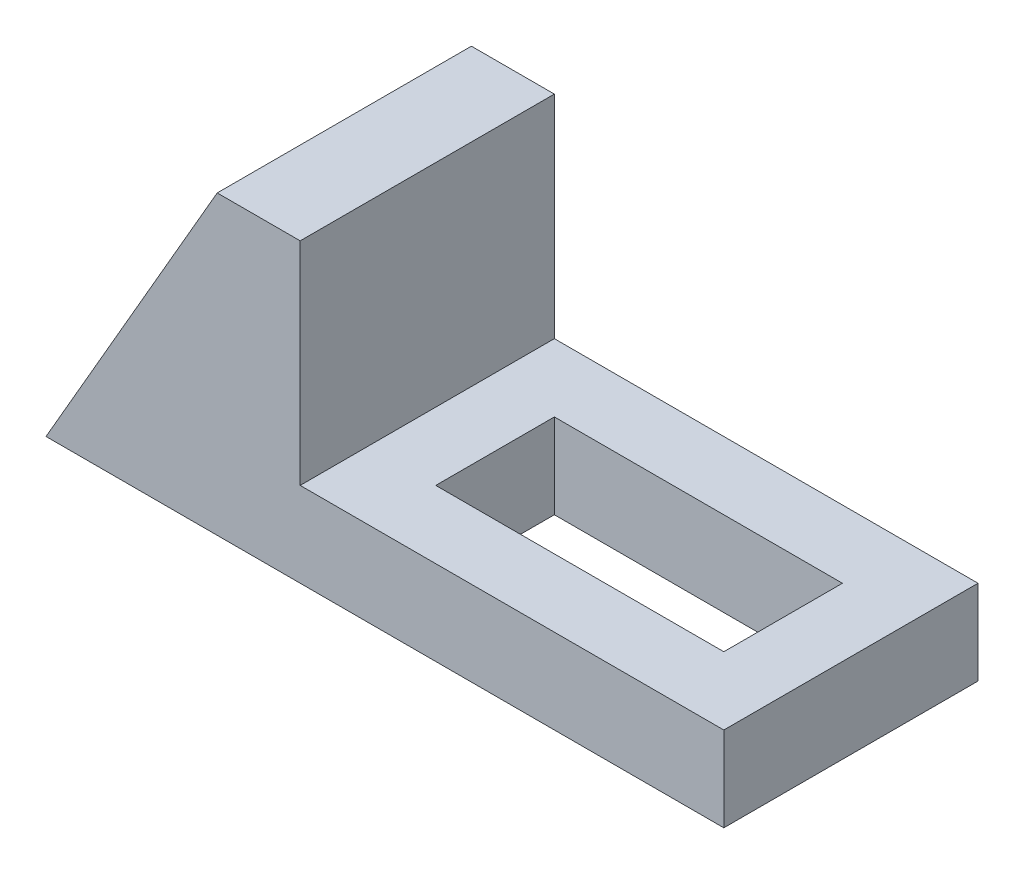
from build123d import *

# Parameters (mm, degrees)
BOSS_EXTRUDE1_DEPTH = 30
SKETCH2_W           = 34
SKETCH2_H           = 14
CUT_EXTRUDE1_DEPTH  = 30


with BuildPart() as part:
    # Sketch1 → Boss-Extrude1 (new body)
    with BuildSketch(Plane.XY):
        Polygon((0, 0), (20.207259422, 35), (30, 35), (30, 10), (80, 10), (80, 0), align=None)
    extrude(amount=BOSS_EXTRUDE1_DEPTH)

    # Sketch2 → Cut-Extrude1 (cut)
    with BuildSketch(Plane(origin=(0, 10, 0), x_dir=(1, 0, 0), z_dir=(0, 1, 0))):
        with Locations((55, -15)):
            Rectangle(SKETCH2_W, SKETCH2_H)
    extrude(amount=-CUT_EXTRUDE1_DEPTH, mode=Mode.SUBTRACT)


solid = part.part
